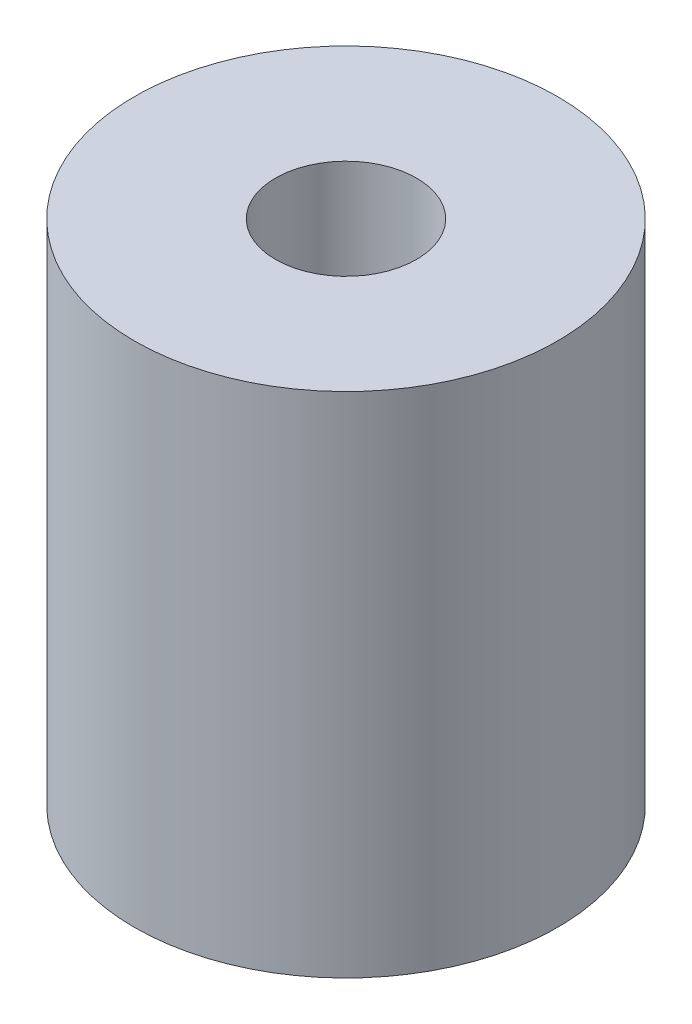
from build123d import *

# Parameters (mm, degrees)
ESQUISSE1_R      = 15
ESQUISSE1_R_2    = 5
EXTRUSION1_DEPTH = 36


with BuildPart() as part:
    # Esquisse1 → Extrusion1 (new body)
    with BuildSketch(Plane(origin=(0, 0, 0), x_dir=(1, 0, 0), z_dir=(0, 1, 0))):
        Circle(ESQUISSE1_R)
        Circle(ESQUISSE1_R_2, mode=Mode.SUBTRACT)
    extrude(amount=EXTRUSION1_DEPTH)


solid = part.part
